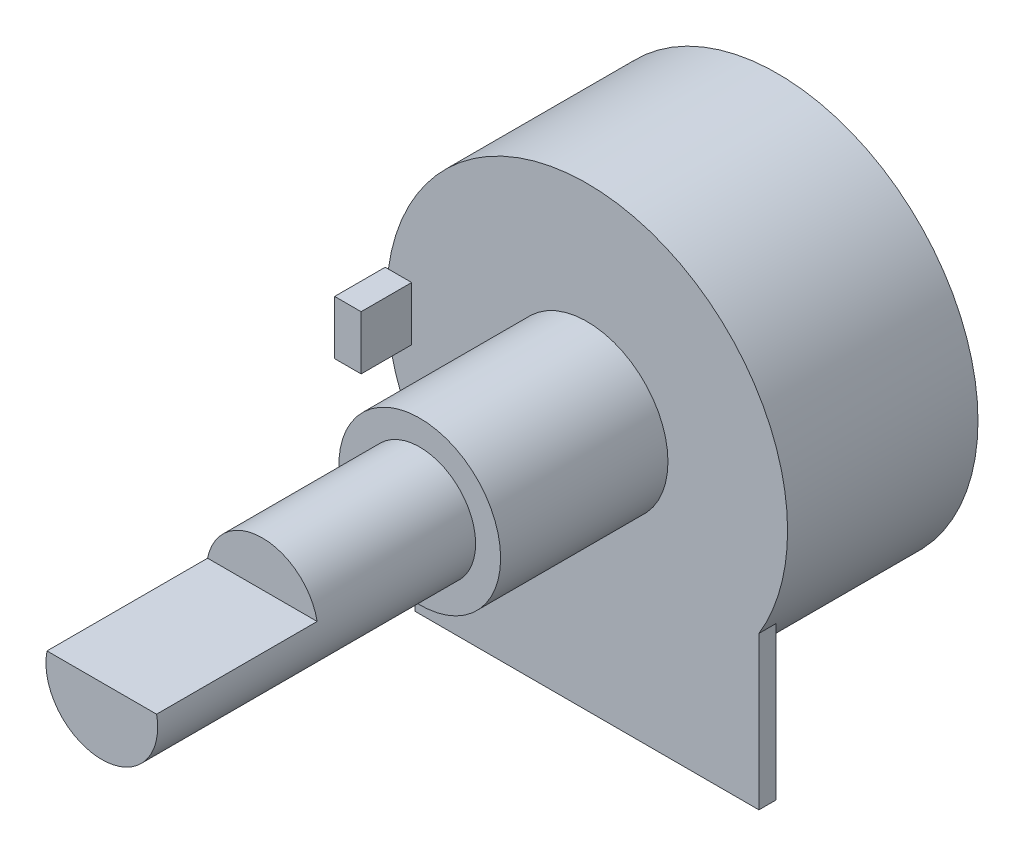
from build123d import *

# Parameters (mm, degrees)
CROQUIS2_W                 = 1.57
CROQUIS2_H                 = 3.2
SALIENTE_EXTRUIR1_DEPTH    = 3
SALIENTE_EXTRUIR2_DEPTH    = 1
CROQUIS4_W                 = 9.53
CROQUIS4_H                 = 2.67
CORTAR_EXTRUIR1_DEPTH      = 12.9
CORTAR_EXTRUIR1_DEPTH_BACK = 12.98


with BuildPart() as part:
    # Croquis1 → Revolución2 (revolve)
    with BuildSketch(Plane(origin=(0, 0, 0), x_dir=(0, 0, -1), z_dir=(1, 0, 0))):
        Polygon((0, 0), (11.3, 0), (11.3, 11.9), (0, 11.9), (0, 4.8), (-9.93, 4.8), (-9.93, 3.315), (-28.8, 3.315), (-28.8, 0), align=None)
    revolve(axis=Axis((0, 0, 28.8), (0, 0, -1)))

    # Croquis2 → Saliente-Extruir1 (add)
    with BuildSketch(Plane.XY):
        with Locations((-11.195, 0)):
            Rectangle(CROQUIS2_W, CROQUIS2_H)
    extrude(amount=SALIENTE_EXTRUIR1_DEPTH)

    # Croquis3 → Saliente-Extruir2 (add)
    with BuildSketch(Plane.XY):
        with BuildLine():
            Line((-10.2, -15.2), (10.2, -15.2))
            Line((10.2, -15.2), (10.2, -6.129437168))
            ThreePointArc((10.2, -6.129437168), (0, -11.9), (-10.2, -6.129437168))
            Line((-10.2, -6.129437168), (-10.2, -15.2))
        make_face()
    extrude(amount=-SALIENTE_EXTRUIR2_DEPTH)

    # Croquis4 → Cortar-Extruir1 (cut, two sides)
    with BuildSketch(Plane(origin=(0, 0, 0), x_dir=(0, 0, -1), z_dir=(1, 0, 0))) as cortar_extruir1_sk:
        with Locations((-24.035, 1.98)):
            Rectangle(CROQUIS4_W, CROQUIS4_H)
    extrude(amount=CORTAR_EXTRUIR1_DEPTH, mode=Mode.SUBTRACT)
    extrude(cortar_extruir1_sk.sketch, amount=-CORTAR_EXTRUIR1_DEPTH_BACK, mode=Mode.SUBTRACT)


solid = part.part
